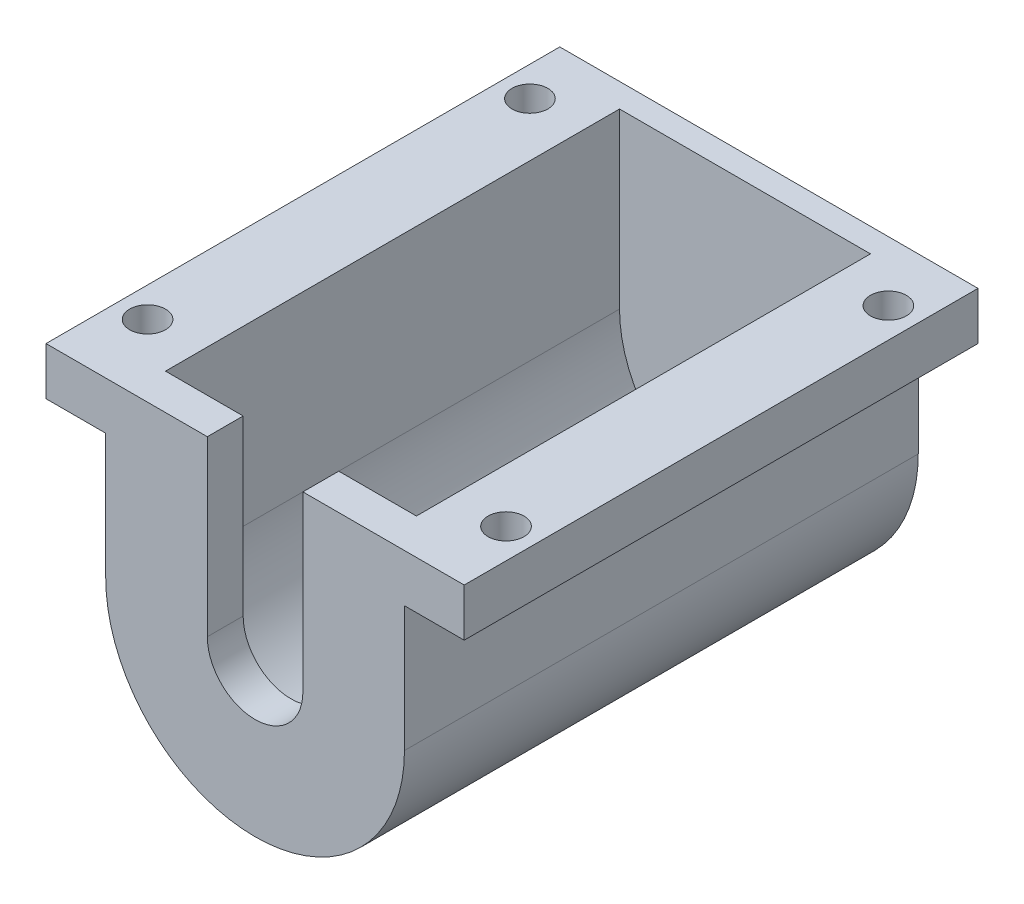
from build123d import *

# Parameters (mm, degrees)
SALIENTE_EXTRUIR1_DEPTH = 38
SALIENTE_EXTRUIR2_DEPTH = 3
SALIENTE_EXTRUIR3_DEPTH = 2
CROQUIS4_R              = 1.5
SALIENTE_EXTRUIR4_DEPTH = 4


with BuildPart() as part:
    # Croquis1 → Saliente-Extruir1 (new body)
    with BuildSketch(Plane.XY):
        with BuildLine():
            Line((-10.5, 0), (-10.5, 10.5))
            Line((-10.5, 10.5), (-12.5, 10.5))
            Line((-12.5, 10.5), (-12.5, 0))
            ThreePointArc((-12.5, 0), (0, -12.5), (12.5, 0))
            Line((12.5, 0), (12.5, 10.5))
            Line((12.5, 10.5), (10.5, 10.5))
            Line((10.5, 10.5), (10.5, 0))
            ThreePointArc((10.5, 0), (0, -10.5), (-10.5, 0))
        make_face()
    extrude(amount=SALIENTE_EXTRUIR1_DEPTH)

    # Croquis2 → Saliente-Extruir2 (add)
    with BuildSketch(Plane.XY.offset(38)):
        with BuildLine():
            Line((-12.5, 10.5), (-4, 10.5))
            Line((-4, 10.5), (-4, 0))
            ThreePointArc((-4, 0), (0, -4), (4, 0))
            Line((4, 0), (4, 10.5))
            Line((4, 10.5), (12.5, 10.5))
            Line((12.5, 10.5), (12.5, 0))
            ThreePointArc((12.5, 0), (0, -12.5), (-12.5, 0))
            Line((-12.5, 0), (-12.5, 10.5))
        make_face()
    extrude(amount=SALIENTE_EXTRUIR2_DEPTH)

    # Croquis3 → Saliente-Extruir3 (add)
    with BuildSketch(Plane(origin=(0, 0, 0), x_dir=(-1, 0, 0), z_dir=(0, 0, -1))):
        with BuildLine():
            Line((-12.5, 10.5), (12.5, 10.5))
            Line((12.5, 10.5), (12.5, 0))
            ThreePointArc((12.5, 0), (0, -12.5), (-12.5, 0))
            Line((-12.5, 0), (-12.5, 10.5))
        make_face()
    extrude(amount=SALIENTE_EXTRUIR3_DEPTH)

    # Croquis4 → Saliente-Extruir4 (add)
    with BuildSketch(Plane(origin=(0, 10.5, 0), x_dir=(1, 0, 0), z_dir=(0, 1, 0))):
        Polygon((-17.5, 2), (17.5, 2), (17.5, -41), (4, -41), (4, -38), (10.5, -38), (10.5, 0), (-10.5, 0), (-10.5, -38), (-4, -38), (-4, -41), (-17.5, -41), align=None)
        with Locations((-15, -3)):
            Circle(CROQUIS4_R, mode=Mode.SUBTRACT)
        with Locations((15, -3)):
            Circle(CROQUIS4_R, mode=Mode.SUBTRACT)
        with Locations((15, -35)):
            Circle(CROQUIS4_R, mode=Mode.SUBTRACT)
        with Locations((-15, -35)):
            Circle(CROQUIS4_R, mode=Mode.SUBTRACT)
    extrude(amount=SALIENTE_EXTRUIR4_DEPTH)


solid = part.part
